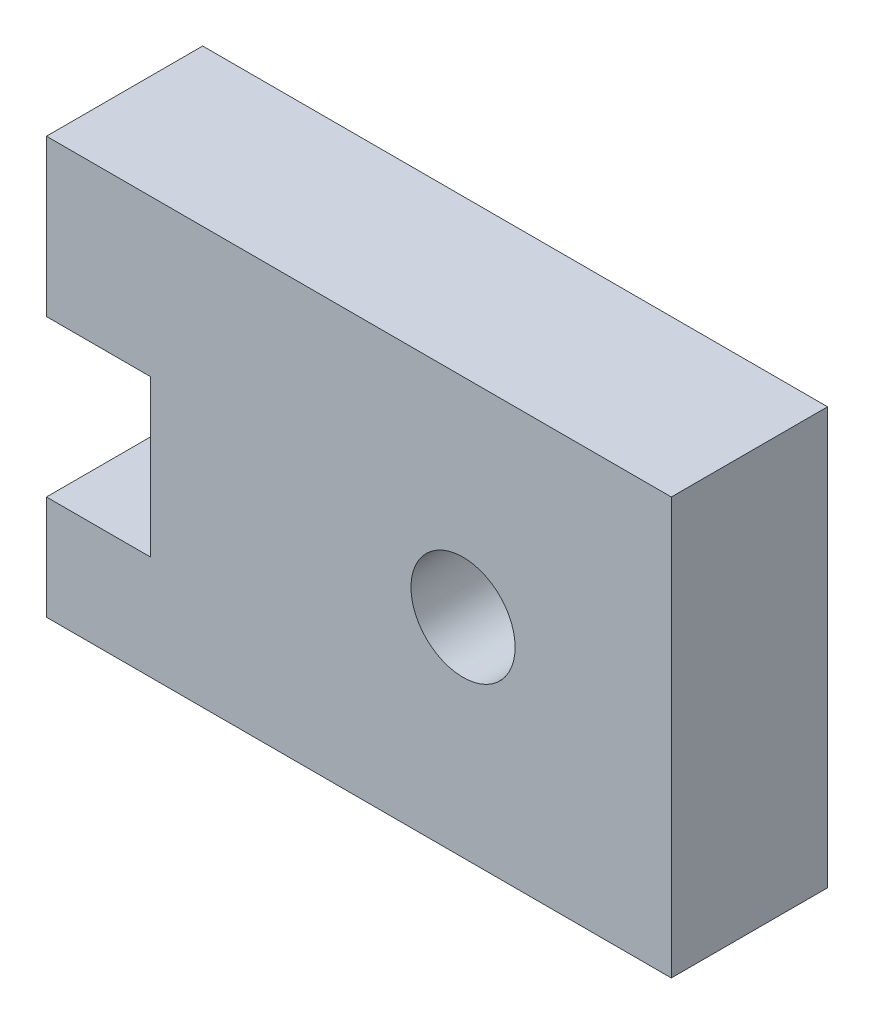
from build123d import *

# Parameters (mm, degrees)
SKETCH1_R           = 1.5875
BOSS_EXTRUDE1_DEPTH = 4.7625


with BuildPart() as part:
    # Sketch1 → Boss-Extrude1 (new body)
    with BuildSketch(Plane.XY):
        Polygon((0, 3.175), (0, 0), (19.05, 0), (19.05, 12.7), (0, 12.7), (0, 7.9375), (3.175, 7.9375), (3.175, 3.175), align=None)
        with Locations((12.7, 6.35)):
            Circle(SKETCH1_R, mode=Mode.SUBTRACT)
    extrude(amount=BOSS_EXTRUDE1_DEPTH)


solid = part.part
